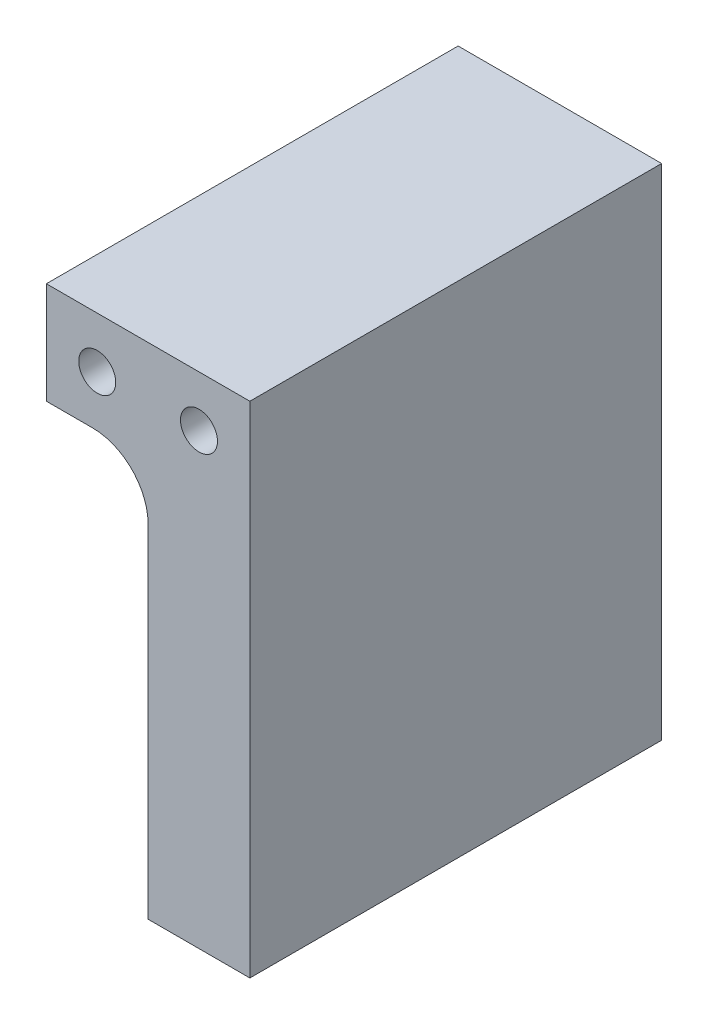
from build123d import *

# Parameters (mm, degrees)
BOSS_EXTRUDE1_DEPTH    = 222.57
F_20_0MM_DOWEL_HOLE1_D = 20


with BuildPart() as part:
    # Sketch1 → Boss-Extrude1 (new body)
    with BuildSketch(Plane.XY):
        with BuildLine():
            Line((0, 0), (-110, 0))
            Line((-110, 0), (-110, -55))
            Line((-110, -55), (-85, -55))
            ThreePointArc((-85, -55), (-63.786796564, -63.786796564), (-55, -85))
            Line((-55, -85), (-55, -270))
            Line((-55, -270), (0, -270))
            Line((0, -270), (0, 0))
        make_face()
    extrude(amount=BOSS_EXTRUDE1_DEPTH)

    # Ø20.0mm Dowel Hole1 (through all)
    with Locations(Plane.XY.offset(222.57)):
        with Locations((-82.5, -27.5), (-27.5, -27.5)):
            Hole(F_20_0MM_DOWEL_HOLE1_D / 2)


solid = part.part
